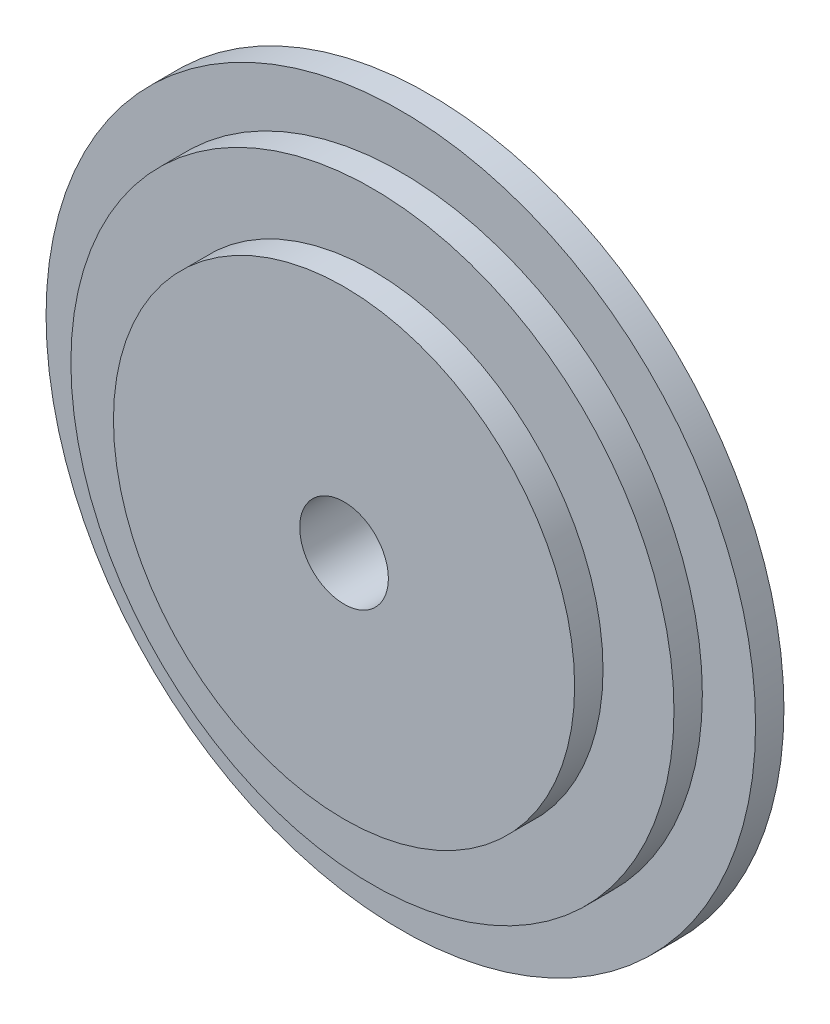
from build123d import *

# Parameters (mm, degrees)
ESBO_O1_R                = 100
RESSALTO_EXTRUS_O1_DEPTH = 8
ESBO_O4_R                = 85
RESSALTO_EXTRUS_O2_DEPTH = 8
ESBO_O5_R                = 65
RESSALTO_EXTRUS_O4_DEPTH = 8
ESBO_O6_R                = 12.5
CORTE_EXTRUS_O1_DEPTH    = 25


with BuildPart() as part:
    # Esboço1 → Ressalto-extrusão1 (new body)
    with BuildSketch(Plane.XY):
        Circle(ESBO_O1_R)
    extrude(amount=RESSALTO_EXTRUS_O1_DEPTH)

    # Esboço4 → Ressalto-extrusão2 (add)
    with BuildSketch(Plane.XY.offset(8)):
        Circle(ESBO_O4_R)
    extrude(amount=RESSALTO_EXTRUS_O2_DEPTH)

    # Esboço5 → Ressalto-extrusão4 (add)
    with BuildSketch(Plane.XY.offset(16)):
        Circle(ESBO_O5_R)
    extrude(amount=RESSALTO_EXTRUS_O4_DEPTH)

    # Esboço6 → Corte-extrusão1 (cut, through all)
    with BuildSketch(Plane.XY.offset(24)):
        Circle(ESBO_O6_R)
    extrude(amount=-CORTE_EXTRUS_O1_DEPTH, mode=Mode.SUBTRACT)


solid = part.part
